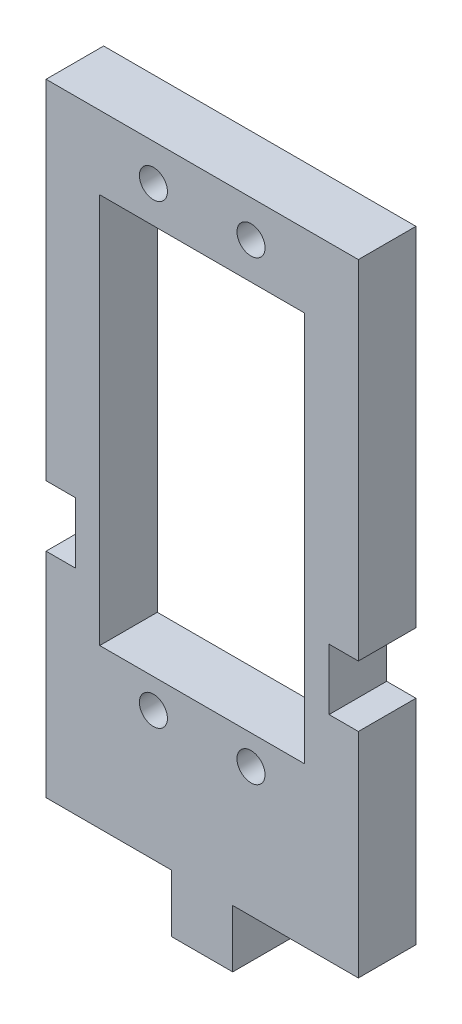
from build123d import *

# Parameters (mm, degrees)
SKETCH1_R           = 1.4605
SKETCH1_W           = 21.336
SKETCH1_H           = 40.64
BOSS_EXTRUDE1_DEPTH = 5.9944


with BuildPart() as part:
    # Sketch1 → Boss-Extrude1 (new body)
    with BuildSketch(Plane.XY):
        Polygon((-3.175, -5.9944), (3.175, -5.9944), (3.175, 0), (16.256, 0), (16.256, 22.225), (13.208, 22.225), (13.208, 28.575), (16.256, 28.575), (16.256, 64.77), (-16.256, 64.77), (-16.256, 28.575), (-13.208, 28.575), (-13.208, 22.225), (-16.256, 22.225), (-16.256, 0), (-3.175, 0), align=None)
        with Locations((5.08, 60.96)):
            Circle(SKETCH1_R, mode=Mode.SUBTRACT)
        with Locations((5.08, 13.462)):
            Circle(SKETCH1_R, mode=Mode.SUBTRACT)
        with Locations((-5.08, 13.462)):
            Circle(SKETCH1_R, mode=Mode.SUBTRACT)
        with Locations((-5.08, 60.96)):
            Circle(SKETCH1_R, mode=Mode.SUBTRACT)
        with Locations((0, 36.83)):
            Rectangle(SKETCH1_W, SKETCH1_H, mode=Mode.SUBTRACT)
    extrude(amount=BOSS_EXTRUDE1_DEPTH)


solid = part.part
